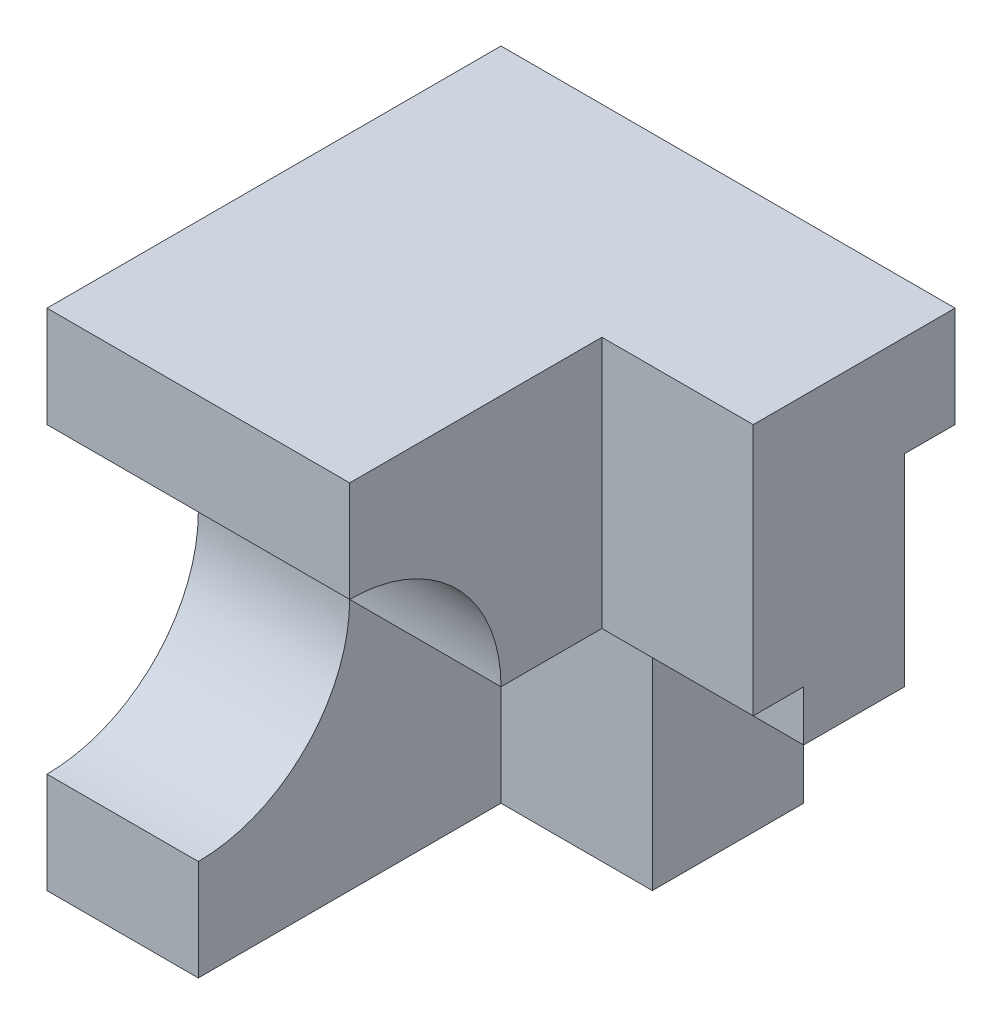
from build123d import *

# Parameters (mm, degrees)
BOSS_EXTRUDE1_DEPTH = 9
CUT_EXTRUDE1_DEPTH  = 3
SKETCH5_W           = 6
SKETCH5_H           = 5
CUT_EXTRUDE2_DEPTH  = 6


with BuildPart() as part:
    # Sketch1 → Boss-Extrude1 (new body)
    with BuildSketch(Plane(origin=(0, 0, 0), x_dir=(0, 0, -1), z_dir=(1, 0, 0))):
        with BuildLine():
            Line((-4.5, -5), (4.5, -5))
            Line((4.5, -5), (4.5, -3))
            Line((4.5, -3), (3.5, -3))
            Line((3.5, -3), (3.5, 3))
            Line((3.5, 3), (4.5, 3))
            Line((4.5, 3), (4.5, 5))
            Line((4.5, 5), (-4.5, 5))
            Line((-4.5, 5), (-4.5, 3))
            ThreePointArc((-4.5, 3), (-2.378679656, 2.121320344), (-1.5, 0))
            ThreePointArc((-1.5, 0), (-2.378679656, -2.121320344), (-4.5, -3))
            Line((-4.5, -3), (-4.5, -5))
        make_face()
    extrude(amount=BOSS_EXTRUDE1_DEPTH)

    # Sketch3 → Cut-Extrude1 (cut)
    with BuildSketch(Plane(origin=(9, 0, 0), x_dir=(0, 0, -1), z_dir=(1, 0, 0))):
        with BuildLine():
            ThreePointArc((-4.5, 3), (-2.378679656, 2.121320344), (-1.5, 0))
            Line((-1.5, 0), (0.5, 0))
            Line((0.5, 0), (0.5, 5))
            Line((0.5, 5), (-4.5, 5))
            Line((-4.5, 5), (-4.5, 3))
        make_face()
        Polygon((1.5, -1), (1.5, -5), (4.5, -5), (4.5, -3), (3.5, -3), (3.5, -1), align=None)
    extrude(amount=-CUT_EXTRUDE1_DEPTH, mode=Mode.SUBTRACT)

    # Sketch5 → Cut-Extrude2 (cut)
    with BuildSketch(Plane(origin=(9, 0, 0), x_dir=(0, 0, -1), z_dir=(1, 0, 0))):
        with Locations((-1.5, -2.5)):
            Rectangle(SKETCH5_W, SKETCH5_H)
    extrude(amount=-CUT_EXTRUDE2_DEPTH, mode=Mode.SUBTRACT)


solid = part.part
